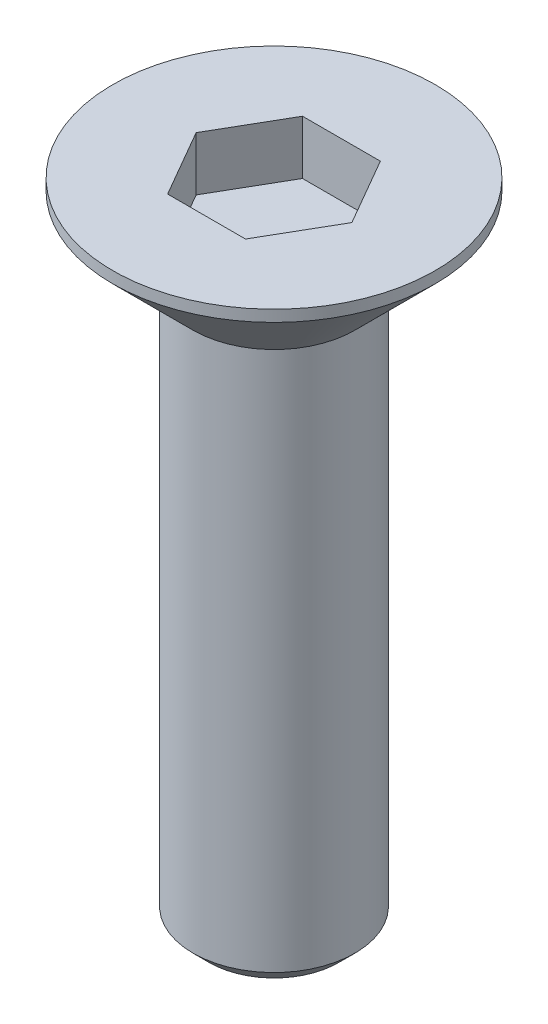
from build123d import *

# Parameters (mm, degrees)
CHAFL_N2_SIZE         = 0.3
CHAFL_N2_SIZE2        = 0.212132034
CHAFL_N3_SIZE         = 0.3
CORTAR_EXTRUIR2_DEPTH = 1


with BuildPart() as part:
    # Croquis1 → Revolución1 (revolve)
    with BuildSketch(Plane.XY, mode=Mode.PRIVATE) as revoluci_n1_sk:
        Polygon((0, 0), (3.2, 0), (1.5, -1.7), (1.5, -12), (0, -12), align=None)
    revolve(revoluci_n1_sk.sketch.rotate(Axis((0, 0, 0), (0, -1, 0)), 90), axis=Axis((0, 0, 0), (0, -1, 0)))

    # Chaflán2
    chafl_n2_edges = [part.edges().sort_by_distance(p)[0] for p in [
        (0, 0, -3.2),
    ]]
    chafl_n2_side = [part.faces().sort_by_distance(p)[0] for p in [
        (0, -0.85, -2.35),
    ]]
    chamfer(chafl_n2_edges, length=CHAFL_N2_SIZE, length2=CHAFL_N2_SIZE2, reference=chafl_n2_side[0])

    # Chaflán3
    chafl_n3_edges = [part.edges().sort_by_distance(p)[0] for p in [
        (0, -12, -1.5),
    ]]
    chamfer(chafl_n3_edges, length=CHAFL_N3_SIZE)

    # Croquis3 → Cortar-Extruir2 (cut)
    with BuildSketch(Plane(origin=(0, 0, 0), x_dir=(1, 0, 0), z_dir=(0, 1, 0))):
        Polygon((-0.721687836, 1.25), (-1.443375673, 0), (-0.721687836, -1.25), (0.721687836, -1.25), (1.443375673, 0), (0.721687836, 1.25), align=None)
    extrude(amount=-CORTAR_EXTRUIR2_DEPTH, mode=Mode.SUBTRACT)


solid = part.part
